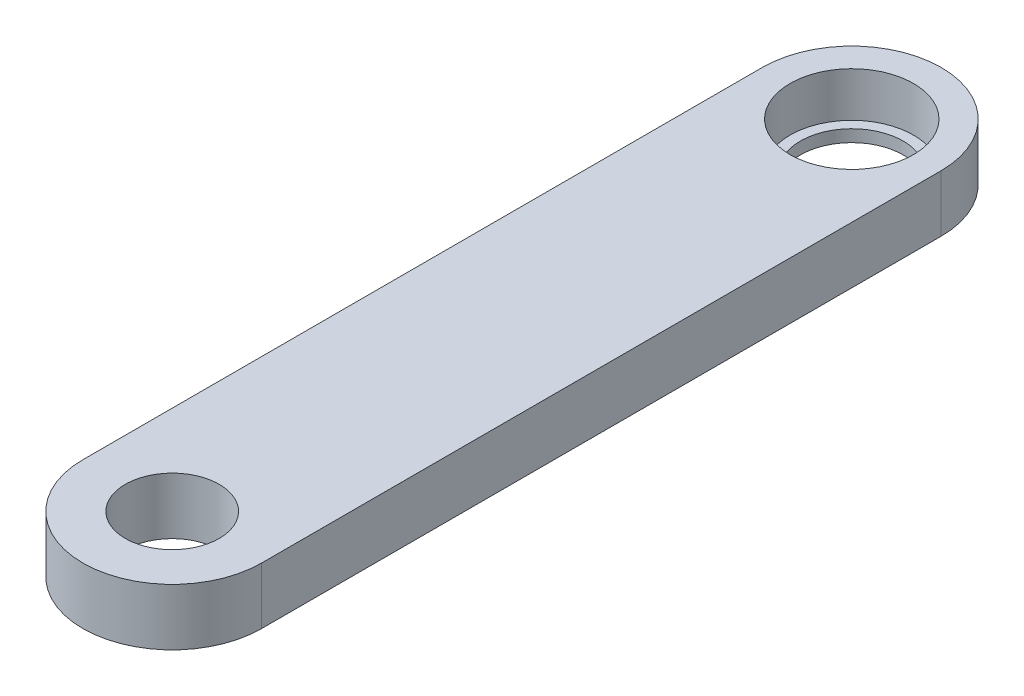
from build123d import *

# Parameters (mm, degrees)
SKETCH1_W           = 10
SKETCH1_H           = 38
BOSS_EXTRUDE1_DEPTH = 1.5875
SKETCH2_R           = 3.45
CUT_EXTRUDE1_DEPTH  = 2.5
SKETCH3_R           = 2.875
CUT_EXTRUDE2_DEPTH  = 1.675
SKETCH4_R           = 2.625
CUT_EXTRUDE3_DEPTH  = 4.175


with BuildPart() as part:
    # Sketch1 → Boss-Extrude1 (new body, symmetric)
    with BuildSketch(Plane(origin=(0, 0, 0), x_dir=(1, 0, 0), z_dir=(0, 1, 0))):
        with BuildLine():
            ThreePointArc((-5, 19), (0, 24), (5, 19))
            Line((5, 19), (-5, 19))
        make_face()
        Rectangle(SKETCH1_W, SKETCH1_H)
        with BuildLine():
            Line((5, -19), (-5, -19))
            ThreePointArc((-5, -19), (0, -24), (5, -19))
        make_face()
    extrude(amount=BOSS_EXTRUDE1_DEPTH, both=True)

    # Sketch2 → Cut-Extrude1 (cut)
    with BuildSketch(Plane(origin=(0, 1.5875, 0), x_dir=(1, 0, 0), z_dir=(0, 1, 0))):
        with Locations((0, 19)):
            Circle(SKETCH2_R)
    extrude(amount=-CUT_EXTRUDE1_DEPTH, mode=Mode.SUBTRACT)

    # Sketch3 → Cut-Extrude2 (cut, through all)
    with BuildSketch(Plane(origin=(0, -0.9125, 0), x_dir=(1, 0, 0), z_dir=(0, 1, 0))):
        with Locations((0, 19)):
            Circle(SKETCH3_R)
    extrude(amount=-CUT_EXTRUDE2_DEPTH, mode=Mode.SUBTRACT)

    # Sketch4 → Cut-Extrude3 (cut, through all)
    with BuildSketch(Plane(origin=(0, 1.5875, 0), x_dir=(1, 0, 0), z_dir=(0, 1, 0))):
        with Locations((0, -19)):
            Circle(SKETCH4_R)
    extrude(amount=-CUT_EXTRUDE3_DEPTH, mode=Mode.SUBTRACT)


solid = part.part
